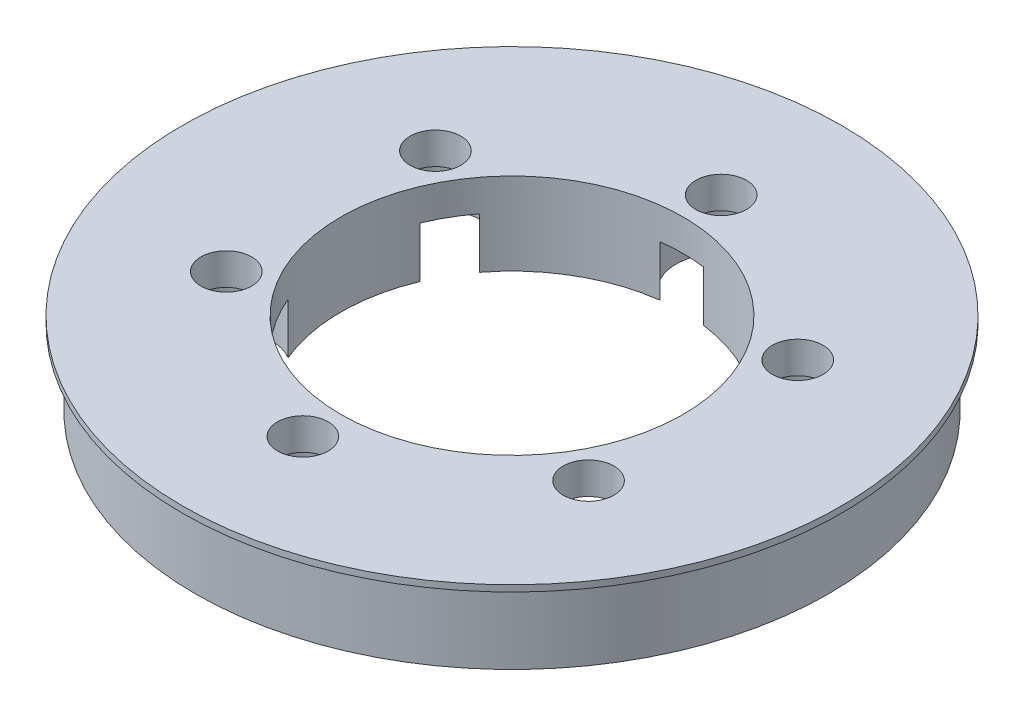
from build123d import *

# Parameters (mm, degrees)
SKETCH1_R           = 25
SKETCH1_R_2         = 13.5
BOSS_EXTRUDE1_DEPTH = 6
SKETCH2_R           = 2
CUT_EXTRUDE1_DEPTH  = 36.860842154
SKETCH3_R           = 3.55
CUT_EXTRUDE4_DEPTH  = 4
CIRPATTERN2_COUNT   = 6
SKETCH4_R           = 26
SKETCH4_R_2         = 2
SKETCH4_R_3         = 13.5
BOSS_EXTRUDE3_DEPTH = 0.5


with BuildPart() as part:
    # Sketch1 → Boss-Extrude1 (new body)
    with BuildSketch(Plane(origin=(0, 0, 0), x_dir=(1, 0, 0), z_dir=(0, 1, 0))):
        with Locations(Location((0, 0, 0), (0, 0, 270))):
            Circle(SKETCH1_R)
        with Locations(Location((0, 0, 0), (0, 0, 270))):
            Circle(SKETCH1_R_2, mode=Mode.SUBTRACT)
    extrude(amount=BOSS_EXTRUDE1_DEPTH)

    # Sketch2 → Cut-Extrude1 (cut, through all)
    with BuildSketch(Plane(origin=(0, 6, 0), x_dir=(1, 0, 0), z_dir=(0, 1, 0))):
        with Locations(Location((0, 16.5, 0), (0, 0, 270))):
            Circle(SKETCH2_R)
    cut_extrude1 = extrude(amount=-CUT_EXTRUDE1_DEPTH, mode=Mode.SUBTRACT)

    # Sketch3 → Cut-Extrude4 (cut)
    with BuildSketch(Plane(origin=(0, 0, 0), x_dir=(1, 0, 0), z_dir=(0, 1, 0))):
        with Locations((0, 16.5)):
            Circle(SKETCH3_R)
    cut_extrude4 = extrude(amount=CUT_EXTRUDE4_DEPTH, mode=Mode.SUBTRACT)

    # CirPattern2: Cut-Extrude1, Cut-Extrude4 ×6 about axis
    cirpattern2_axis = Axis((0, 0, 0), (0, 1, 0))
    add([cut_extrude1.rotate(cirpattern2_axis, i * 360 / CIRPATTERN2_COUNT) for i in range(1, CIRPATTERN2_COUNT)], mode=Mode.SUBTRACT)
    add([cut_extrude4.rotate(cirpattern2_axis, i * 360 / CIRPATTERN2_COUNT) for i in range(1, CIRPATTERN2_COUNT)], mode=Mode.SUBTRACT)

    # Sketch4 → Boss-Extrude3 (add)
    with BuildSketch(Plane(origin=(0, 6, 0), x_dir=(1, 0, 0), z_dir=(0, 1, 0))):
        with Locations(Location((0, 0, 0), (0, 0, 270))):
            Circle(SKETCH4_R)
        with Locations(Location((14.289419162, 8.25, 0), (0, 0, 270))):
            Circle(SKETCH4_R_2, mode=Mode.SUBTRACT)
        with Locations(Location((14.289419162, -8.25, 0), (0, 0, 270))):
            Circle(SKETCH4_R_2, mode=Mode.SUBTRACT)
        with Locations(Location((0, -16.5, 0), (0, 0, 270))):
            Circle(SKETCH4_R_2, mode=Mode.SUBTRACT)
        with Locations(Location((0, 0, 0), (0, 0, 82.708634602))):
            Circle(SKETCH4_R_3, mode=Mode.SUBTRACT)
        with Locations(Location((-14.289419162, -8.25, 0), (0, 0, 270))):
            Circle(SKETCH4_R_2, mode=Mode.SUBTRACT)
        with Locations(Location((-14.289419162, 8.25, 0), (0, 0, 270))):
            Circle(SKETCH4_R_2, mode=Mode.SUBTRACT)
        with Locations(Location((0, 16.5, 0), (0, 0, 270))):
            Circle(SKETCH4_R_2, mode=Mode.SUBTRACT)
    extrude(amount=BOSS_EXTRUDE3_DEPTH)


solid = part.part
